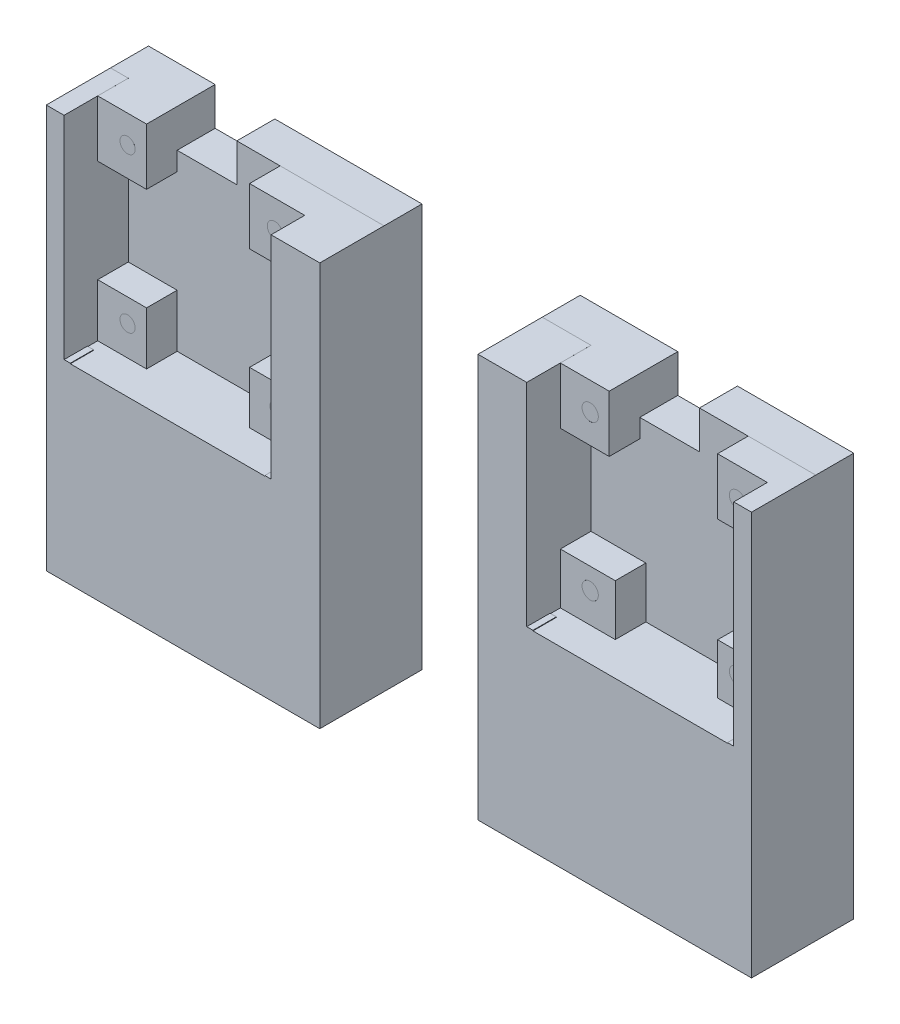
from build123d import *

# Parameters (mm, degrees)
SKETCH2_W            = 130
SKETCH2_H            = 40
BOSS_EXTRUDE1_DEPTH  = 75
SKETCH6_W            = 29.16
SKETCH6_H            = 49.32
BOSS_EXTRUDE2_DEPTH  = 16.07
SKETCH7_W            = 15.96
SKETCH7_H            = 42.65
CUT_EXTRUDE1_DEPTH   = 8.48
SKETCH8_W            = 7
SKETCH8_H            = 42.65
CUT_EXTRUDE2_DEPTH   = 1.145
SKETCH9_W            = 7
SKETCH9_H            = 42.65
CUT_EXTRUDE3_DEPTH   = 1.145
SKETCH11_W           = 35.86
SKETCH11_H           = 21.1
CUT_EXTRUDE4_DEPTH   = 8.2
SKETCH13_W           = 3.9
SKETCH13_H           = 21.1
CUT_EXTRUDE5_DEPTH   = 1.145
SKETCH14_W           = 3.9
SKETCH14_H           = 21.1
CUT_EXTRUDE6_DEPTH   = 1.145
SKETCH15_W           = 35.86
SKETCH15_H           = 21.1
CUT_EXTRUDE7_DEPTH   = 8.2
SKETCH16_W           = 3.9
SKETCH16_H           = 21.1
CUT_EXTRUDE8_DEPTH   = 1.145
SKETCH17_W           = 3.9
SKETCH17_H           = 21.1
CUT_EXTRUDE9_DEPTH   = 1.145
SKETCH20_W           = 29.16
SKETCH20_H           = 16.07
BOSS_EXTRUDE3_DEPTH  = 25.68
SKETCH21_W           = 40
SKETCH21_H           = 25
CUT_EXTRUDE10_DEPTH  = 40
SKETCH22_W           = 50
SKETCH22_H           = 25
CUT_EXTRUDE11_DEPTH  = 40
BOSS_EXTRUDE4_DEPTH  = 8
BOSS_EXTRUDE5_DEPTH  = 8
SKETCH25_W           = 130
SKETCH25_H           = 26.637321837
CUT_EXTRUDE12_DEPTH  = 57.07
SKETCH26_W           = 130
SKETCH26_H           = 25
BOSS_EXTRUDE6_DEPTH  = 40
SKETCH27_W           = 29.16
SKETCH27_H           = 48.362678163
CUT_EXTRUDE13_DEPTH  = 57.07
BOSS_EXTRUDE9_DEPTH  = 26
BOSS_EXTRUDE10_DEPTH = 26
SKETCH32_W           = 38.15
SKETCH32_H           = 39.1
SKETCH32_R           = 2.5
CUT_EXTRUDE14_DEPTH  = 24
SKETCH33_R           = 1.4
BOSS_EXTRUDE11_DEPTH = 2
SKETCH34_W           = 1.145
SKETCH34_H           = 4.3
CUT_EXTRUDE15_DEPTH  = 39
SKETCH35_W           = 38.15
SKETCH35_H           = 39.1
SKETCH35_R           = 2.5
CUT_EXTRUDE16_DEPTH  = 24
SKETCH36_W           = 1.145
SKETCH36_H           = 4.3
CUT_EXTRUDE17_DEPTH  = 39
SKETCH37_R           = 1.5
BOSS_EXTRUDE12_DEPTH = 2
SKETCH41_W           = 11
SKETCH41_H           = 5.5
CUT_EXTRUDE18_DEPTH  = 8.8
SKETCH42_W           = 11
SKETCH42_H           = 5.5
CUT_EXTRUDE19_DEPTH  = 8.8
SKETCH43_R           = 3
CUT_EXTRUDE20_DEPTH  = 10
SKETCH44_R           = 3
CUT_EXTRUDE21_DEPTH  = 10
SKETCH45_W           = 50.42
SKETCH45_H           = 28.159053891
CUT_EXTRUDE22_DEPTH  = 90
SKETCH46_W           = 50.42
SKETCH46_H           = 28.159053891
CUT_EXTRUDE23_DEPTH  = 90
SKETCH47_W           = 50.42
SKETCH47_H           = 7
BOSS_EXTRUDE13_DEPTH = 7
SKETCH48_W           = 50.42
SKETCH48_H           = 7
BOSS_EXTRUDE14_DEPTH = 67.36
SKETCH49_W           = 11
SKETCH49_H           = 7
CUT_EXTRUDE24_DEPTH  = 8
SKETCH50_W           = 9
SKETCH50_H           = 10.425354422
SKETCH50_H_2         = 9.756007641
SKETCH50_W_2         = 10.161312311
SKETCH50_H_3         = 9.656007641
SKETCH50_H_4         = 10.428032585
BOSS_EXTRUDE15_DEPTH = 5.64
SKETCH51_W           = 9
SKETCH51_H           = 10.425354422
SKETCH51_W_2         = 9.167731693
SKETCH51_H_2         = 10.428032585
SKETCH51_W_3         = 10.119146351
SKETCH51_H_3         = 9.404026774
SKETCH51_H_4         = 9.304026774
BOSS_EXTRUDE16_DEPTH = 5.64


with BuildPart() as part:
    # Sketch2 → Boss-Extrude1 (new body)
    with BuildSketch(Plane(origin=(0, 0, 0), x_dir=(1, 0, 0), z_dir=(0, 1, 0))):
        Rectangle(SKETCH2_W, SKETCH2_H)
    extrude(amount=BOSS_EXTRUDE1_DEPTH)

    # Sketch6 → Boss-Extrude2 (add)
    with BuildSketch(Plane.XY.offset(20)):
        with Locations((0, 50.34)):
            Rectangle(SKETCH6_W, SKETCH6_H)
    extrude(amount=BOSS_EXTRUDE2_DEPTH)

    # Sketch7 → Cut-Extrude1 (cut)
    with BuildSketch(Plane.XY.offset(36.07)):
        with Locations((0, 53.675)):
            Rectangle(SKETCH7_W, SKETCH7_H)
    extrude(amount=-CUT_EXTRUDE1_DEPTH, mode=Mode.SUBTRACT)

    # Sketch8 → Cut-Extrude2 (cut)
    with BuildSketch(Plane(origin=(-7.98, 0, 0), x_dir=(0, 0, -1), z_dir=(1, 0, 0))):
        with Locations((-31.09, 53.675)):
            Rectangle(SKETCH8_W, SKETCH8_H)
    extrude(amount=-CUT_EXTRUDE2_DEPTH, mode=Mode.SUBTRACT)

    # Sketch9 → Cut-Extrude3 (cut)
    with BuildSketch(Plane.ZY.offset(-7.98)):
        with Locations((31.09, 53.675)):
            Rectangle(SKETCH9_W, SKETCH9_H)
    extrude(amount=-CUT_EXTRUDE3_DEPTH, mode=Mode.SUBTRACT)

    # Sketch11 → Cut-Extrude4 (cut)
    with BuildSketch(Plane.XY.offset(20)):
        with Locations((42.64, 64.45)):
            Rectangle(SKETCH11_W, SKETCH11_H)
    extrude(amount=-CUT_EXTRUDE4_DEPTH, mode=Mode.SUBTRACT)

    # Sketch13 → Cut-Extrude5 (cut)
    with BuildSketch(Plane(origin=(24.71, 0, 0), x_dir=(0, 0, -1), z_dir=(1, 0, 0))):
        with Locations((-13.75, 64.45)):
            Rectangle(SKETCH13_W, SKETCH13_H)
    extrude(amount=-CUT_EXTRUDE5_DEPTH, mode=Mode.SUBTRACT)

    # Sketch14 → Cut-Extrude6 (cut)
    with BuildSketch(Plane.ZY.offset(-60.57)):
        with Locations((13.75, 64.45)):
            Rectangle(SKETCH14_W, SKETCH14_H)
    extrude(amount=-CUT_EXTRUDE6_DEPTH, mode=Mode.SUBTRACT)

    # Sketch15 → Cut-Extrude7 (cut)
    with BuildSketch(Plane.XY.offset(20)):
        with Locations((-42.64, 64.45)):
            Rectangle(SKETCH15_W, SKETCH15_H)
    extrude(amount=-CUT_EXTRUDE7_DEPTH, mode=Mode.SUBTRACT)

    # Sketch16 → Cut-Extrude8 (cut)
    with BuildSketch(Plane(origin=(-60.57, 0, 0), x_dir=(0, 0, -1), z_dir=(1, 0, 0))):
        with Locations((-13.75, 64.45)):
            Rectangle(SKETCH16_W, SKETCH16_H)
    extrude(amount=-CUT_EXTRUDE8_DEPTH, mode=Mode.SUBTRACT)

    # Sketch17 → Cut-Extrude9 (cut)
    with BuildSketch(Plane.ZY.offset(24.71)):
        with Locations((13.75, 64.45)):
            Rectangle(SKETCH17_W, SKETCH17_H)
    extrude(amount=-CUT_EXTRUDE9_DEPTH, mode=Mode.SUBTRACT)

    # Sketch20 → Boss-Extrude3 (add)
    with BuildSketch(Plane(origin=(0, 25.68, 0), x_dir=(-1, 0, 0), z_dir=(0, -1, 0))):
        with Locations((0, -28.035)):
            Rectangle(SKETCH20_W, SKETCH20_H)
    extrude(amount=BOSS_EXTRUDE3_DEPTH)

    # Sketch21 → Cut-Extrude10 (cut)
    with BuildSketch(Plane(origin=(0, 75, 0), x_dir=(1, 0, 0), z_dir=(0, 1, 0))):
        with Locations((45, 7.5)):
            Rectangle(SKETCH21_W, SKETCH21_H)
        with Locations((-45, 7.5)):
            Rectangle(SKETCH21_W, SKETCH21_H)
    extrude(amount=-CUT_EXTRUDE10_DEPTH, mode=Mode.SUBTRACT)

    # Sketch22 → Cut-Extrude11 (cut)
    with BuildSketch(Plane(origin=(0, 75, 0), x_dir=(1, 0, 0), z_dir=(0, 1, 0))):
        with Locations((0, 7.5)):
            Rectangle(SKETCH22_W, SKETCH22_H)
    extrude(amount=-CUT_EXTRUDE11_DEPTH, mode=Mode.SUBTRACT)

    # Sketch23 → Boss-Extrude4 (add)
    with BuildSketch(Plane(origin=(0, 53.9, 0), x_dir=(1, 0, 0), z_dir=(0, 1, 0))):
        Polygon((-60.57, -20), (-60.57, -15.7), (-61.715, -15.7), (-61.715, -11.8), (-23.565, -11.8), (-23.565, -15.7), (-24.71, -15.7), (-24.71, -20), align=None)
    extrude(amount=BOSS_EXTRUDE4_DEPTH)

    # Sketch24 → Boss-Extrude5 (add)
    with BuildSketch(Plane(origin=(0, 53.9, 0), x_dir=(1, 0, 0), z_dir=(0, 1, 0))):
        Polygon((24.71, -20), (24.71, -15.7), (23.565, -15.7), (23.565, -11.8), (61.715, -11.8), (61.715, -15.7), (60.57, -15.7), (60.57, -20), align=None)
    extrude(amount=BOSS_EXTRUDE5_DEPTH)

    # Sketch25 → Cut-Extrude12 (cut, through all)
    with BuildSketch(Plane.XY.offset(36.07)):
        with Locations((0, 13.318660919)):
            Rectangle(SKETCH25_W, SKETCH25_H)
    extrude(amount=-CUT_EXTRUDE12_DEPTH, mode=Mode.SUBTRACT)

    # Sketch26 → Boss-Extrude6 (add)
    with BuildSketch(Plane(origin=(0, 35, 0), x_dir=(1, 0, 0), z_dir=(0, 1, 0))):
        with Locations((0, 7.5)):
            Rectangle(SKETCH26_W, SKETCH26_H)
    extrude(amount=BOSS_EXTRUDE6_DEPTH)

    # Sketch27 → Cut-Extrude13 (cut, through all)
    with BuildSketch(Plane.XY.offset(36.07)):
        with Locations((0, 50.818660919)):
            Rectangle(SKETCH27_W, SKETCH27_H)
    extrude(amount=-CUT_EXTRUDE13_DEPTH, mode=Mode.SUBTRACT)

    # Sketch30 → Boss-Extrude9 (add)
    with BuildSketch(Plane(origin=(0, 75, 0), x_dir=(1, 0, 0), z_dir=(0, 1, 0))):
        Polygon((-65, 20), (-65, -20), (-60.57, -20), (-60.57, -15.7), (-61.715, -15.7), (-61.715, -11.8), (-23.565, -11.8), (-23.565, -15.7), (-24.71, -15.7), (-24.71, -20), (-14.58, -20), (-14.58, 20), align=None)
    extrude(amount=BOSS_EXTRUDE9_DEPTH)

    # Sketch31 → Boss-Extrude10 (add)
    with BuildSketch(Plane(origin=(0, 75, 0), x_dir=(1, 0, 0), z_dir=(0, 1, 0))):
        Polygon((14.58, 20), (14.58, -20), (24.71, -20), (24.71, -15.7), (23.565, -15.7), (23.565, -11.8), (61.715, -11.8), (61.715, -15.7), (60.57, -15.7), (60.57, -20), (65, -20), (65, 20), align=None)
    extrude(amount=BOSS_EXTRUDE10_DEPTH)

    # Sketch32 → Cut-Extrude14 (cut)
    with BuildSketch(Plane.XY.offset(11.8)):
        with Locations((-42.64, 81.45)):
            Rectangle(SKETCH32_W, SKETCH32_H)
        with Locations((-56.215, 95.9)):
            Circle(SKETCH32_R, mode=Mode.SUBTRACT)
        with Locations((-56.215, 67.4)):
            Circle(SKETCH32_R, mode=Mode.SUBTRACT)
        with Locations((-29.065, 95.895613698)):
            Circle(SKETCH32_R, mode=Mode.SUBTRACT)
        with Locations((-28.565, 67.4)):
            Circle(SKETCH32_R, mode=Mode.SUBTRACT)
    extrude(amount=-CUT_EXTRUDE14_DEPTH, mode=Mode.SUBTRACT)

    # Sketch33 → Boss-Extrude11 (add)
    with BuildSketch(Plane.XY.offset(11.8)):
        with Locations((-56.215, 95.9)):
            Circle(SKETCH33_R)
        with Locations((-56.215, 67.4)):
            Circle(SKETCH33_R)
        with Locations((-29.065, 95.895613698)):
            Circle(SKETCH33_R)
        with Locations((-28.565, 67.4)):
            Circle(SKETCH33_R)
    extrude(amount=BOSS_EXTRUDE11_DEPTH)

    # Sketch34 → Cut-Extrude15 (cut)
    with BuildSketch(Plane(origin=(0, 101, 0), x_dir=(1, 0, 0), z_dir=(0, 1, 0))):
        with Locations((-61.1425, -17.85)):
            Rectangle(SKETCH34_W, SKETCH34_H)
        with Locations((-24.1375, -17.85)):
            Rectangle(SKETCH34_W, SKETCH34_H)
    extrude(amount=-CUT_EXTRUDE15_DEPTH, mode=Mode.SUBTRACT)

    # Sketch35 → Cut-Extrude16 (cut)
    with BuildSketch(Plane.XY.offset(11.8)):
        with Locations((42.64, 81.45)):
            Rectangle(SKETCH35_W, SKETCH35_H)
        with Locations((29.065, 67.4)):
            Circle(SKETCH35_R, mode=Mode.SUBTRACT)
        with Locations((29.065, 95.9)):
            Circle(SKETCH35_R, mode=Mode.SUBTRACT)
        with Locations((56.215, 67.4)):
            Circle(SKETCH35_R, mode=Mode.SUBTRACT)
        with Locations((56.215, 95.5)):
            Circle(SKETCH35_R, mode=Mode.SUBTRACT)
    extrude(amount=-CUT_EXTRUDE16_DEPTH, mode=Mode.SUBTRACT)

    # Sketch36 → Cut-Extrude17 (cut)
    with BuildSketch(Plane(origin=(0, 101, 0), x_dir=(1, 0, 0), z_dir=(0, 1, 0))):
        with Locations((24.1375, -17.85)):
            Rectangle(SKETCH36_W, SKETCH36_H)
        with Locations((61.1425, -17.85)):
            Rectangle(SKETCH36_W, SKETCH36_H)
    extrude(amount=-CUT_EXTRUDE17_DEPTH, mode=Mode.SUBTRACT)

    # Sketch37 → Boss-Extrude12 (add)
    with BuildSketch(Plane.XY.offset(11.8)):
        with Locations((29.065, 95.9)):
            Circle(SKETCH37_R)
        with Locations((29.065, 67.4)):
            Circle(SKETCH37_R)
        with Locations((56.215, 95.5)):
            Circle(SKETCH37_R)
        with Locations((56.215, 67.4)):
            Circle(SKETCH37_R)
    extrude(amount=BOSS_EXTRUDE12_DEPTH)

    # Sketch41 → Cut-Extrude18 (cut, through all)
    with BuildSketch(Plane.XY.offset(-12.2)):
        with Locations((-46.215, 98.25)):
            Rectangle(SKETCH41_W, SKETCH41_H)
    extrude(amount=-CUT_EXTRUDE18_DEPTH, mode=Mode.SUBTRACT)

    # Sketch42 → Cut-Extrude19 (cut, through all)
    with BuildSketch(Plane.XY.offset(-12.2)):
        with Locations((39.065, 98.25)):
            Rectangle(SKETCH42_W, SKETCH42_H)
    extrude(amount=-CUT_EXTRUDE19_DEPTH, mode=Mode.SUBTRACT)

    # Sketch43 → Cut-Extrude20 (cut)
    with BuildSketch(Plane(origin=(0, 26.637321837, 0), x_dir=(-1, 0, 0), z_dir=(0, -1, 0))):
        with Locations((60, -15)):
            Circle(SKETCH43_R)
        with Locations((60, 15)):
            Circle(SKETCH43_R)
        with Locations((19.58, -15)):
            Circle(SKETCH43_R)
        with Locations((19.58, 15)):
            Circle(SKETCH43_R)
    extrude(amount=-CUT_EXTRUDE20_DEPTH, mode=Mode.SUBTRACT)

    # Sketch44 → Cut-Extrude21 (cut)
    with BuildSketch(Plane.XZ.offset(-26.637321837)):
        with Locations((19.58, 15)):
            Circle(SKETCH44_R)
        with Locations((19.58, -15)):
            Circle(SKETCH44_R)
        with Locations((60, 15)):
            Circle(SKETCH44_R)
        with Locations((60, -15)):
            Circle(SKETCH44_R)
    extrude(amount=-CUT_EXTRUDE21_DEPTH, mode=Mode.SUBTRACT)

    # Sketch45 → Cut-Extrude22 (cut)
    with BuildSketch(Plane(origin=(0, 101, 0), x_dir=(1, 0, 0), z_dir=(0, 1, 0))):
        with Locations((39.79, 5.920473054)):
            Rectangle(SKETCH45_W, SKETCH45_H)
    extrude(amount=-CUT_EXTRUDE22_DEPTH, mode=Mode.SUBTRACT)

    # Sketch46 → Cut-Extrude23 (cut)
    with BuildSketch(Plane(origin=(0, 101, 0), x_dir=(1, 0, 0), z_dir=(0, 1, 0))):
        with Locations((-39.79, 5.920473054)):
            Rectangle(SKETCH46_W, SKETCH46_H)
    extrude(amount=-CUT_EXTRUDE23_DEPTH, mode=Mode.SUBTRACT)

    # Sketch47 → Boss-Extrude13 (add)
    with BuildSketch(Plane(origin=(0, 0, 8.159053891), x_dir=(-1, 0, 0), z_dir=(0, 0, -1))):
        with Locations((-39.79, 30.137321837)):
            Rectangle(SKETCH47_W, SKETCH47_H)
        with Locations((39.79, 30.137321837)):
            Rectangle(SKETCH47_W, SKETCH47_H)
    extrude(amount=BOSS_EXTRUDE13_DEPTH)

    # Sketch48 → Boss-Extrude14 (add)
    with BuildSketch(Plane(origin=(0, 33.637321837, 0), x_dir=(1, 0, 0), z_dir=(0, 1, 0))):
        with Locations((39.79, -4.659053891)):
            Rectangle(SKETCH48_W, SKETCH48_H)
        with Locations((-39.79, -4.659053891)):
            Rectangle(SKETCH48_W, SKETCH48_H)
    extrude(amount=BOSS_EXTRUDE14_DEPTH)

    # Sketch49 → Cut-Extrude24 (cut, through all)
    with BuildSketch(Plane.XY.offset(8.159053891)):
        with Locations((-47.215, 97.497321837)):
            Rectangle(SKETCH49_W, SKETCH49_H)
        with Locations((38.065, 97.497321837)):
            Rectangle(SKETCH49_W, SKETCH49_H)
    extrude(amount=-CUT_EXTRUDE24_DEPTH, mode=Mode.SUBTRACT)

    # Sketch50 → Boss-Extrude15 (add)
    with BuildSketch(Plane.XY.offset(8.159053891)):
        with Locations((-57.215, 95.784644626)):
            Rectangle(SKETCH50_W, SKETCH50_H)
        with Locations((-57.215, 66.778003821)):
            Rectangle(SKETCH50_W, SKETCH50_H_2)
        with Locations((-28.645656155, 66.828003821)):
            Rectangle(SKETCH50_W_2, SKETCH50_H_3)
        with Locations((-28.645656155, 95.785983708)):
            Rectangle(SKETCH50_W_2, SKETCH50_H_4)
    extrude(amount=BOSS_EXTRUDE15_DEPTH)

    # Sketch51 → Boss-Extrude16 (add)
    with BuildSketch(Plane.XY.offset(8.159053891)):
        with Locations((28.065, 95.784644626)):
            Rectangle(SKETCH51_W, SKETCH51_H)
        with Locations((57.131134153, 95.785983708)):
            Rectangle(SKETCH51_W_2, SKETCH51_H_2)
        with Locations((28.624573176, 66.602013387)):
            Rectangle(SKETCH51_W_3, SKETCH51_H_3)
        with Locations((57.131134153, 66.652013387)):
            Rectangle(SKETCH51_W_2, SKETCH51_H_4)
    extrude(amount=BOSS_EXTRUDE16_DEPTH)


solid = part.part
